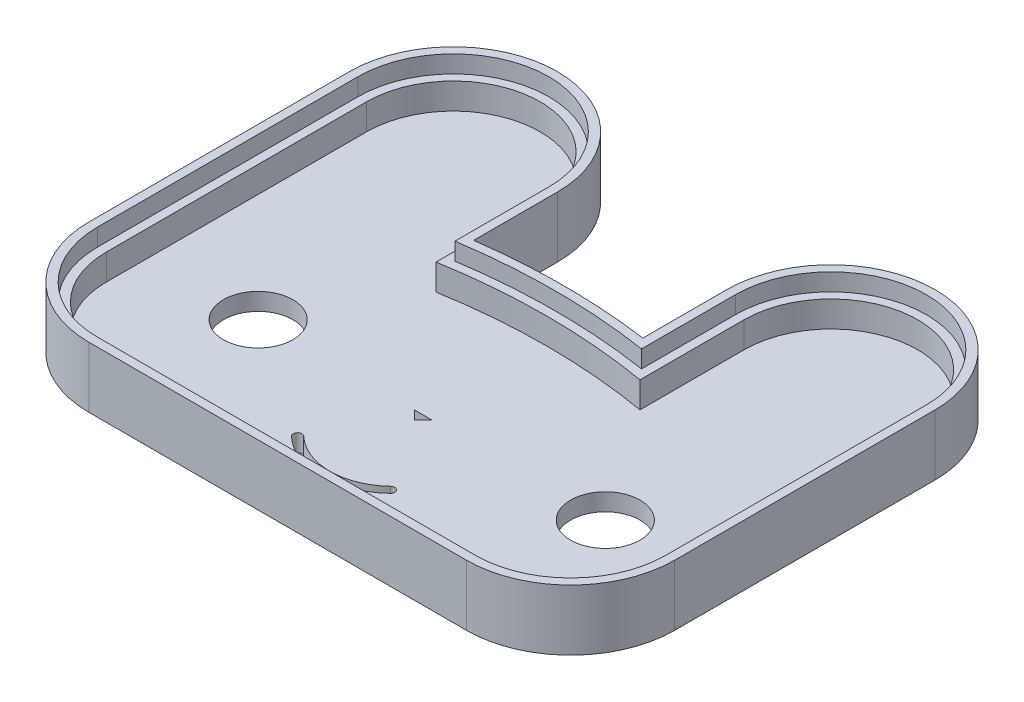
from build123d import *

# Parameters (mm, degrees)
EXTRUDE_1_DEPTH     = 2
EXTRUDE_2_DEPTH     = 5
EXTRUDE_3_DEPTH     = 7
SKETCH_2_R          = 4
CUT_EXTRUDE_1_DEPTH = 9


with BuildPart() as part:
    # 草图1 → 凸台-拉伸1 (new body)
    with BuildSketch(Plane(origin=(0, 0, 0), x_dir=(1, 0, 0), z_dir=(0, 1, 0))):
        with BuildLine():
            Line((-12.333178869, 24.480029994), (-12.333178869, 12.480029994))
            Line((-12.333178869, 12.480029994), (-12.333178869, -5.519970006))
            ThreePointArc((-12.333178869, -5.519970006), (-9.404246681, -12.591037818), (-2.333178869, -15.519970006))
            Line((-2.333178869, -15.519970006), (41.166821131, -15.519970006))
            ThreePointArc((41.166821131, -15.519970006), (48.237888943, -12.591037818), (51.166821131, -5.519970006))
            Line((51.166821131, -5.519970006), (51.166821131, 12.480029994))
            Line((51.166821131, 12.480029994), (51.166821131, 24.480029994))
            ThreePointArc((51.166821131, 24.480029994), (41.166821131, 34.480029994), (31.166821131, 24.480029994))
            Line((31.166821131, 24.480029994), (31.166821131, 12.480029994))
            ThreePointArc((31.166821131, 12.480029994), (19.416821131, 13.480029994), (7.666821131, 12.480029994))
            Line((7.666821131, 12.480029994), (7.666821131, 24.480029994))
            ThreePointArc((7.666821131, 24.480029994), (-2.333178869, 34.480029994), (-12.333178869, 24.480029994))
        make_face()
    extrude(amount=EXTRUDE_1_DEPTH)

    # 草图1<3> → 凸台-拉伸2 (add)
    with BuildSketch(Plane(origin=(0, 0, 0), x_dir=(1, 0, 0), z_dir=(0, 1, 0))):
        with BuildLine():
            Line((30.166821131, 24.480029994), (30.166821131, 13.655987129))
            ThreePointArc((30.166821131, 13.655987129), (19.416821131, 14.480029994), (8.666821131, 13.655987129))
            Line((8.666821131, 13.655987129), (8.666821131, 24.480029994))
            ThreePointArc((8.666821131, 24.480029994), (-2.333178869, 35.480029994), (-13.333178869, 24.480029994))
            Line((-13.333178869, 24.480029994), (-13.333178869, 12.480029994))
            Line((-13.333178869, 12.480029994), (-13.333178869, -5.519970006))
            ThreePointArc((-13.333178869, -5.519970006), (-10.111353462, -13.298144599), (-2.333178869, -16.519970006))
            Line((-2.333178869, -16.519970006), (41.166821131, -16.519970006))
            ThreePointArc((41.166821131, -16.519970006), (48.944995724, -13.298144599), (52.166821131, -5.519970006))
            Line((52.166821131, -5.519970006), (52.166821131, 12.480029994))
            Line((52.166821131, 12.480029994), (52.166821131, 24.480029994))
            ThreePointArc((52.166821131, 24.480029994), (41.166821131, 35.480029994), (30.166821131, 24.480029994))
        make_face()
        with BuildLine():
            Line((-12.333178869, 12.480029994), (-12.333178869, 24.480029994))
            ThreePointArc((-12.333178869, 24.480029994), (-2.333178869, 34.480029994), (7.666821131, 24.480029994))
            Line((7.666821131, 24.480029994), (7.666821131, 12.480029994))
            ThreePointArc((7.666821131, 12.480029994), (19.416821131, 13.480029994), (31.166821131, 12.480029994))
            Line((31.166821131, 12.480029994), (31.166821131, 24.480029994))
            ThreePointArc((31.166821131, 24.480029994), (41.166821131, 34.480029994), (51.166821131, 24.480029994))
            Line((51.166821131, 24.480029994), (51.166821131, 12.480029994))
            Line((51.166821131, 12.480029994), (51.166821131, -5.519970006))
            ThreePointArc((51.166821131, -5.519970006), (48.237888943, -12.591037818), (41.166821131, -15.519970006))
            Line((41.166821131, -15.519970006), (-2.333178869, -15.519970006))
            ThreePointArc((-2.333178869, -15.519970006), (-9.404246681, -12.591037818), (-12.333178869, -5.519970006))
            Line((-12.333178869, -5.519970006), (-12.333178869, 12.480029994))
        make_face(mode=Mode.SUBTRACT)
    extrude(amount=EXTRUDE_2_DEPTH)

    # 草图1<4> → 凸台-拉伸3 (add)
    with BuildSketch(Plane(origin=(0, 0, 0), x_dir=(1, 0, 0), z_dir=(0, 1, 0))):
        with BuildLine():
            Line((-2.333178869, -17.519970006), (41.166821131, -17.519970006))
            ThreePointArc((41.166821131, -17.519970006), (49.652102505, -14.00525138), (53.166821131, -5.519970006))
            Line((53.166821131, -5.519970006), (53.166821131, 12.480029994))
            Line((53.166821131, 12.480029994), (53.166821131, 24.480029994))
            ThreePointArc((53.166821131, 24.480029994), (41.166821131, 36.480029994), (29.166821131, 24.480029994))
            Line((29.166821131, 24.480029994), (29.166821131, 14.81243236))
            ThreePointArc((29.166821131, 14.81243236), (19.416821131, 15.480029994), (9.666821131, 14.81243236))
            Line((9.666821131, 14.81243236), (9.666821131, 24.480029994))
            ThreePointArc((9.666821131, 24.480029994), (-2.333178869, 36.480029994), (-14.333178869, 24.480029994))
            Line((-14.333178869, 24.480029994), (-14.333178869, 12.480029994))
            Line((-14.333178869, 12.480029994), (-14.333178869, -5.519970006))
            ThreePointArc((-14.333178869, -5.519970006), (-10.818460243, -14.00525138), (-2.333178869, -17.519970006))
        make_face()
        with BuildLine():
            Line((30.166821131, 24.480029994), (30.166821131, 13.655987129))
            ThreePointArc((30.166821131, 13.655987129), (19.416821131, 14.480029994), (8.666821131, 13.655987129))
            Line((8.666821131, 13.655987129), (8.666821131, 24.480029994))
            ThreePointArc((8.666821131, 24.480029994), (-2.333178869, 35.480029994), (-13.333178869, 24.480029994))
            Line((-13.333178869, 24.480029994), (-13.333178869, 12.480029994))
            Line((-13.333178869, 12.480029994), (-13.333178869, -5.519970006))
            ThreePointArc((-13.333178869, -5.519970006), (-10.111353462, -13.298144599), (-2.333178869, -16.519970006))
            Line((-2.333178869, -16.519970006), (41.166821131, -16.519970006))
            ThreePointArc((41.166821131, -16.519970006), (48.944995724, -13.298144599), (52.166821131, -5.519970006))
            Line((52.166821131, -5.519970006), (52.166821131, 12.480029994))
            Line((52.166821131, 12.480029994), (52.166821131, 24.480029994))
            ThreePointArc((52.166821131, 24.480029994), (41.166821131, 35.480029994), (30.166821131, 24.480029994))
        make_face(mode=Mode.SUBTRACT)
    extrude(amount=EXTRUDE_3_DEPTH)

    # 草图2 → 切除-拉伸1 (cut)
    with BuildSketch(Plane.XZ):
        with Locations((40.166821131, 0.519970006)):
            Circle(SKETCH_2_R)
        Polygon((19.166821131, 1.519970006), (18.166821131, 0.519970006), (20.166821131, 0.519970006), align=None)
        with Locations((0.166821131, 0.519970006)):
            Circle(SKETCH_2_R)
        with BuildLine():
            ThreePointArc((14.416821131, 9.519970006), (19.416821131, 11.519970006), (24.416821131, 9.519970006))
            ThreePointArc((24.416821131, 9.519970006), (25.123717683, 9.537211385), (25.106476303, 10.244107937))
            ThreePointArc((25.106476303, 10.244107937), (19.416821131, 12.519970006), (13.727165958, 10.244107937))
            ThreePointArc((13.727165958, 10.244107937), (13.709924579, 9.537211385), (14.416821131, 9.519970006))
        make_face()
    extrude(amount=-CUT_EXTRUDE_1_DEPTH, mode=Mode.SUBTRACT)


solid = part.part
